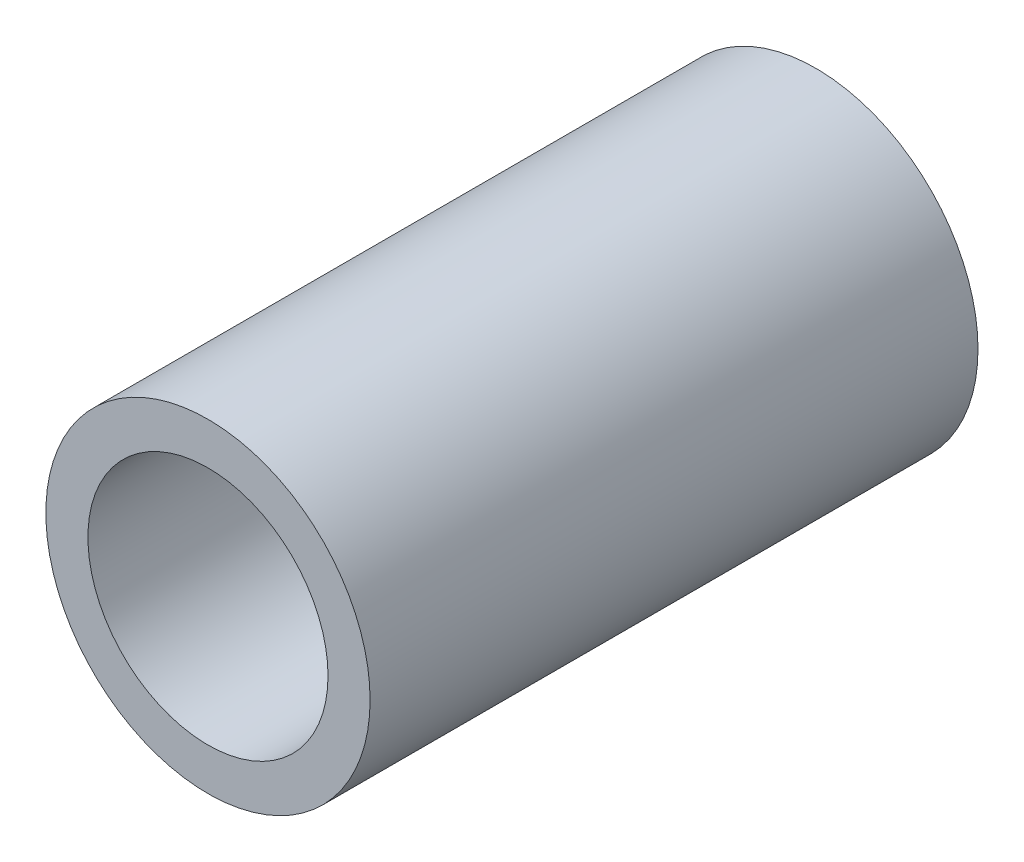
from build123d import *

# Parameters (mm, degrees)
SKETCH1_R           = 10.668
SKETCH1_R_2         = 7.8994
EXTRUDE_THIN1_DEPTH = 20


with BuildPart() as part:
    # Sketch1 → Extrude-Thin1 (new body, symmetric)
    with BuildSketch(Plane.XY):
        Circle(SKETCH1_R)
        Circle(SKETCH1_R_2, mode=Mode.SUBTRACT)
    extrude(amount=EXTRUDE_THIN1_DEPTH, both=True)


solid = part.part
